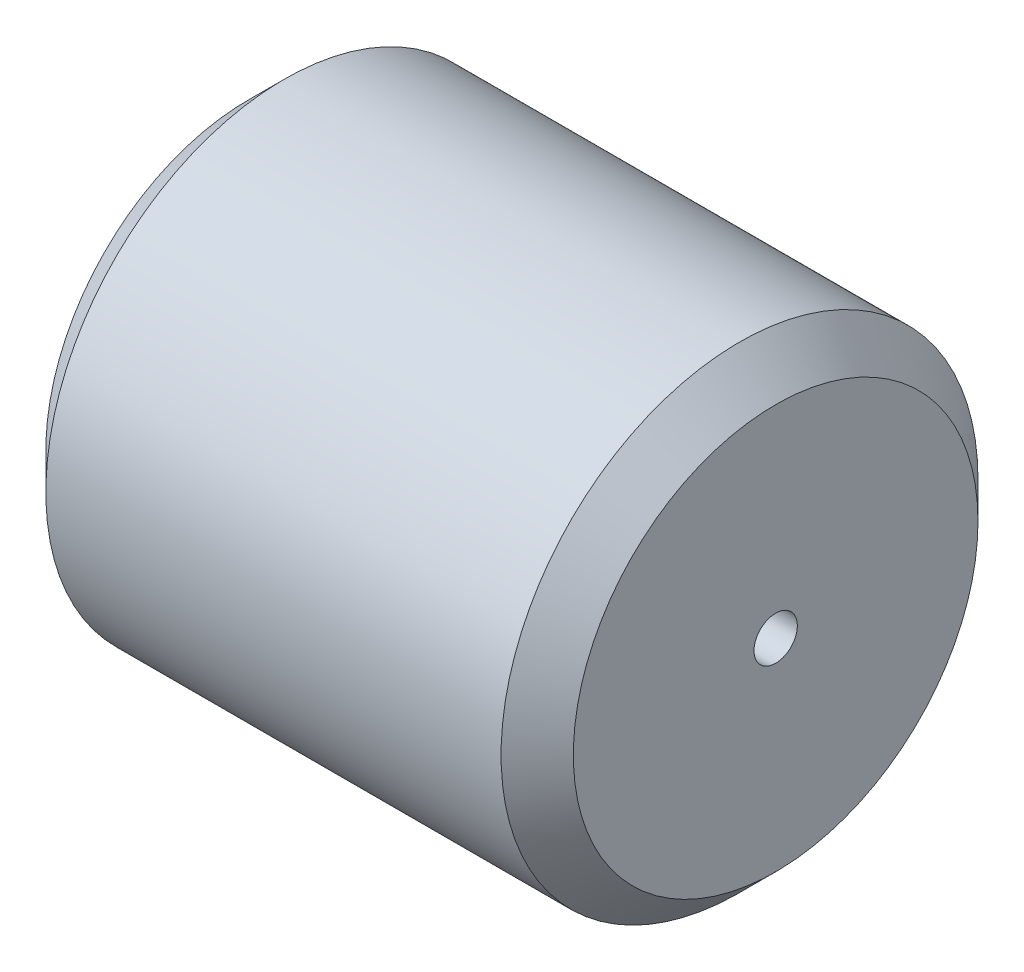
from build123d import *

# Parameters (mm, degrees)
SKETCH1_R           = 33
SKETCH1_R_2         = 3
BOSS_EXTRUDE1_DEPTH = 36.5
CHAMFER1_SIZE       = 5


with BuildPart() as part:
    # Sketch1 → Boss-Extrude1 (new, symmetric)
    with BuildSketch(Plane(origin=(0, 0, 0), x_dir=(0, 0, -1), z_dir=(1, 0, 0))):
        Circle(SKETCH1_R)
        Circle(SKETCH1_R_2, mode=Mode.SUBTRACT)
    extrude(amount=BOSS_EXTRUDE1_DEPTH, both=True)

    # Chamfer1
    chamfer1_edges = [part.edges().sort_by_distance(p)[0] for p in [
        (-36.5, 0, 33),
        (36.5, 0, 33),
    ]]
    chamfer(chamfer1_edges, length=CHAMFER1_SIZE)


solid = part.part
